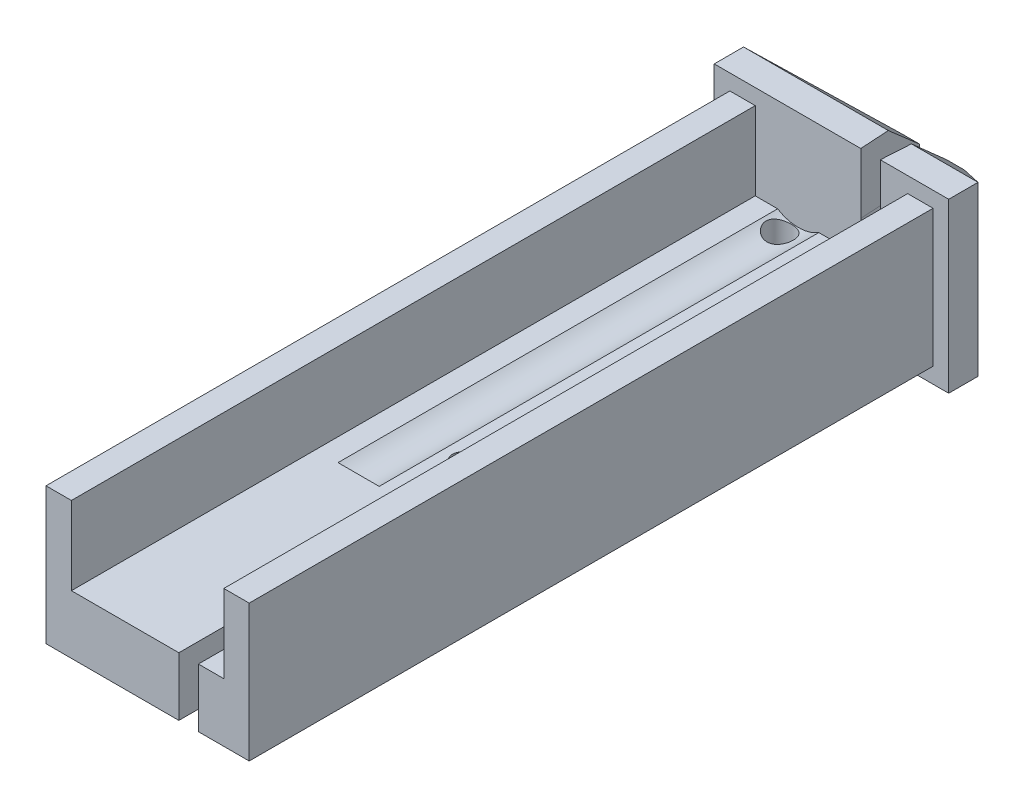
from build123d import *

# Parameters (mm, degrees)
SKETCH4_W           = 8
SKETCH4_H           = 5
EXTRUDE1_DEPTH      = 19.1
SKETCH6_W           = 17.706910835
SKETCH6_H           = 1.662230216
CUT_EXTRUDE1_DEPTH  = 18.6
SKETCH7_W           = 17.592020929
SKETCH7_H           = 1.332722913
CUT_EXTRUDE2_DEPTH  = 18.6
SKETCH8_W           = 5.300719424
SKETCH8_H           = 17.765707434
SKETCH8_W_2         = 2.943884892
SKETCH8_H_2         = 17.795443645
CUT_EXTRUDE3_DEPTH  = 18.6
SKETCH10_W          = 3.9
SKETCH10_H          = 17.990453763
CUT_EXTRUDE4_DEPTH  = 2
SKETCH11_R          = 0.25
CUT_EXTRUDE5_DEPTH  = 2
CUT_EXTRUDE6_DEPTH  = 2
SKETCH14_R          = 0.35
CUT_EXTRUDE8_DEPTH  = 2
CUT_EXTRUDE16_DEPTH = 2.6
CUT_EXTRUDE16_DRAFT = 3.5
SKETCH29_W          = 8
SKETCH29_H          = 5
SKETCH29_W_2        = 6
SKETCH29_H_2        = 4.3
CUT_EXTRUDE19_DEPTH = 2.5
CUT_EXTRUDE20_DEPTH = 5.3
CUT_EXTRUDE21_DEPTH = 7
SKETCH19_R          = 1
CUT_EXTRUDE11_DEPTH = 11.25


with BuildPart() as part:
    # Sketch4 → Extrude1 (new body)
    with BuildSketch(Plane.XY):
        with Locations((-4, 2.5)):
            Rectangle(SKETCH4_W, SKETCH4_H)
    extrude(amount=EXTRUDE1_DEPTH)

    # Sketch6 → Cut-Extrude1 (cut)
    with BuildSketch(Plane(origin=(0, 0, 0), x_dir=(0, 0, -1), z_dir=(1, 0, 0))):
        with Locations((-10.453455418, -0.081115108)):
            Rectangle(SKETCH6_W, SKETCH6_H)
    extrude(amount=-CUT_EXTRUDE1_DEPTH, mode=Mode.SUBTRACT)

    # Sketch7 → Cut-Extrude2 (cut)
    with BuildSketch(Plane(origin=(0, 0, 0), x_dir=(0, 0, -1), z_dir=(1, 0, 0))):
        with Locations((-10.396010465, 4.916361457)):
            Rectangle(SKETCH7_W, SKETCH7_H)
    extrude(amount=-CUT_EXTRUDE2_DEPTH, mode=Mode.SUBTRACT)

    # Sketch8 → Cut-Extrude3 (cut)
    with BuildSketch(Plane.XZ.offset(-0.75)):
        with Locations((-9.250359712, 10.482853717)):
            Rectangle(SKETCH8_W, SKETCH8_H)
        with Locations((0.071942446, 10.497721823)):
            Rectangle(SKETCH8_W_2, SKETCH8_H_2)
    extrude(amount=-CUT_EXTRUDE3_DEPTH, mode=Mode.SUBTRACT)

    # Sketch10 → Cut-Extrude4 (cut)
    with BuildSketch(Plane(origin=(0, 4.25, 0), x_dir=(1, 0, 0), z_dir=(0, 1, 0))):
        with Locations((-4, -10.595226882)):
            Rectangle(SKETCH10_W, SKETCH10_H)
    extrude(amount=-CUT_EXTRUDE4_DEPTH, mode=Mode.SUBTRACT)

    # Sketch11 → Cut-Extrude5 (cut)
    with BuildSketch(Plane(origin=(0, 2.25, 0), x_dir=(1, 0, 0), z_dir=(0, 1, 0))):
        with Locations(Location((-3.85, -11.2, 0), (0, 0, 270))):  # turned: the seam where the file's is
            Circle(SKETCH11_R)
    extrude(amount=-CUT_EXTRUDE5_DEPTH, mode=Mode.SUBTRACT)

    # Sketch12 → Cut-Extrude6 (cut)
    with BuildSketch(Plane(origin=(0, 2.25, 0), x_dir=(1, 0, 0), z_dir=(0, 1, 0))):
        with BuildLine():
            Line((-3.2, -19.099584714), (-3.2, -11.099584714))
            ThreePointArc((-3.2, -11.099584714), (-2.95, -10.849584714), (-2.7, -11.099584714))
            Line((-2.7, -11.099584714), (-2.7, -19.099584714))
            ThreePointArc((-2.7, -19.099584714), (-2.95, -19.349584714), (-3.2, -19.099584714))
        make_face()
    extrude(amount=-CUT_EXTRUDE6_DEPTH, mode=Mode.SUBTRACT)

    # Sketch14 → Cut-Extrude8 (cut)
    with BuildSketch(Plane(origin=(0, 2.25, 0), x_dir=(1, 0, 0), z_dir=(0, 1, 0))):
        with Locations(Location((-4.95, -1.975, 0), (0, 0, 270))):  # turned: the seam where the file's is
            Circle(SKETCH14_R)
    extrude(amount=-CUT_EXTRUDE8_DEPTH, mode=Mode.SUBTRACT)


with BuildPart() as cut_extrude16_tool:
    # Sketch28 → Cut-Extrude16 (with draft: the straight prism first)
    with BuildSketch(Plane.XY.offset(1.6)):
        with BuildLine():
            ThreePointArc((-3.25, 3.1), (-3, 2.85), (-2.75, 3.1))
            Line((-2.75, 3.1), (-2.75, 5))
            Line((-2.75, 5), (-3.25, 5))
            Line((-3.25, 5), (-3.25, 3.1))
        make_face()
    extrude(amount=-CUT_EXTRUDE16_DEPTH)
    # Cut-Extrude16: the draft: its side faces are tilted about the plane it starts from
    cut_extrude16_sides = [cut_extrude16_tool.faces().sort_by_distance(p)[0] for p in [
        (-3, 2.85, 0.3),
        (-2.75, 4.05, 0.3),
        (-3, 5, 0.3),
        (-3.25, 4.05, 0.3),
    ]]
    draft(cut_extrude16_sides, Plane.XY.offset(1.6), CUT_EXTRUDE16_DRAFT)


with BuildPart() as part_1:
    add(part.part)

    # Cut-Extrude16: cut by cut_extrude16_tool
    add(cut_extrude16_tool.part, mode=Mode.SUBTRACT)

    # Sketch29 → Cut-Extrude19 (cut)
    with BuildSketch(Plane.XY.offset(1.6)):
        with Locations((-4, 2.5)):
            Rectangle(SKETCH29_W, SKETCH29_H)
        with Locations((-4, 2.5)):
            Rectangle(SKETCH29_W_2, SKETCH29_H_2, mode=Mode.SUBTRACT)
    extrude(amount=-CUT_EXTRUDE19_DEPTH, mode=Mode.SUBTRACT)

    # Sketch18 → Cut-Extrude20 (cut, through all)
    with BuildSketch(Plane(origin=(0, 4.65, 0), x_dir=(1, 0, 0), z_dir=(0, 1, 0))):
        Polygon((-3.8, 0), (-7, -0.85), (-7, 0), align=None)
        Polygon((-2.2, 0), (-1, 0), (-1, -0.85), align=None)
    extrude(amount=-CUT_EXTRUDE20_DEPTH, mode=Mode.SUBTRACT)

    # Sketch30 → Cut-Extrude21 (cut, through all)
    with BuildSketch(Plane.ZY.offset(7)):
        Polygon((0, 3.9), (0.85, 4.65), (0, 4.65), align=None)
        Polygon((0, 2.3), (0.85, 0.35), (0, 0.35), align=None)
    extrude(amount=-CUT_EXTRUDE21_DEPTH, mode=Mode.SUBTRACT)

    # Sketch19 → Cut-Extrude11 (cut)
    with BuildSketch(Plane.XY.offset(1.6)):
        with Locations((-4.85, 3.1)):
            Circle(SKETCH19_R)
    extrude(amount=CUT_EXTRUDE11_DEPTH, mode=Mode.SUBTRACT)


solid = part_1.part
